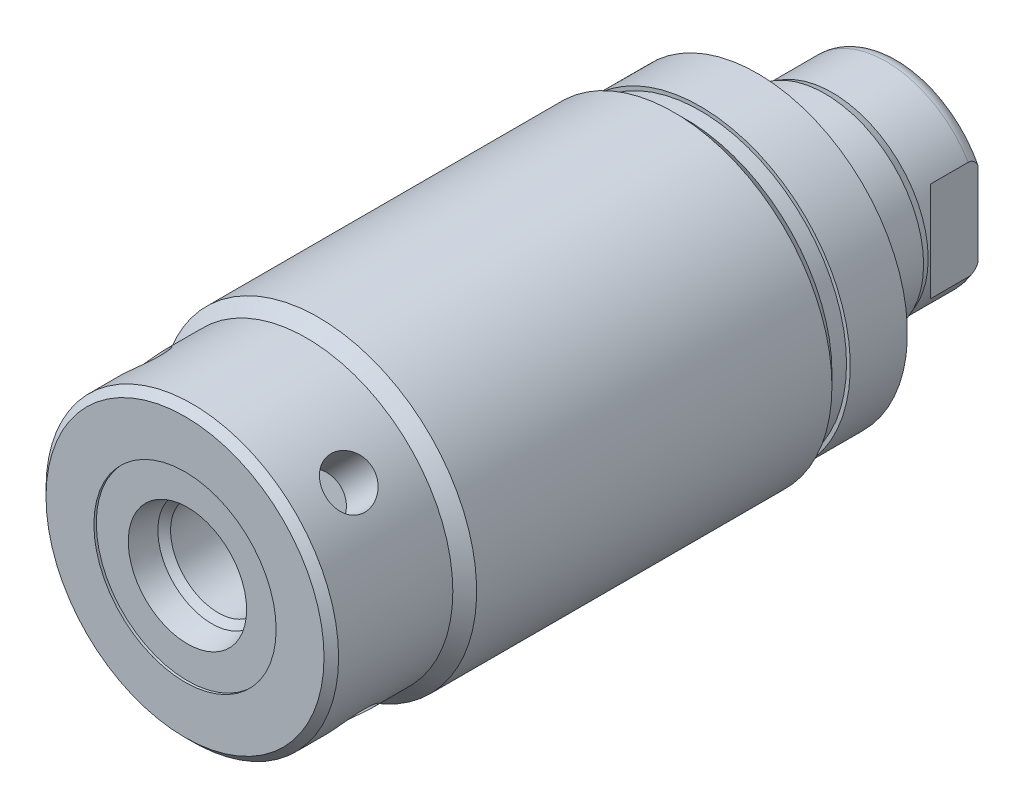
from build123d import *

# Parameters (mm, degrees)
SKETCH1_R          = 16.5354
EXTRUDE1_DEPTH     = 53.848
CHAMFER1_SIZE      = 0.762
SKETCH6_R          = 15.6845
EXTRUDE2_DEPTH     = 5.969
SKETCH7_W          = 14.478
SKETCH7_H          = 10.31875
CUT_EXTRUDE4_DEPTH = 19.84248
HOLE1_D            = 5.0038
HOLE1_DEPTH        = 4.7498
CIRPATTERN1_COUNT  = 4


with BuildPart() as part:
    # Sketch1 → Extrude1 (new body)
    with BuildSketch(Plane.XY):
        Circle(SKETCH1_R)
    extrude(amount=EXTRUDE1_DEPTH)

    # Sketch2 → Cut-Revolve1 (revolve, cut)
    with BuildSketch(Plane(origin=(0, 0, 0), x_dir=(1, 0, 0), z_dir=(0, 1, 0)), mode=Mode.PRIVATE) as cut_revolve1_sk:
        Polygon((16.5354, -53.848), (16.5354, -39.9034), (15.2908, -41.148), (15.2908, -53.848), align=None)
    revolve(cut_revolve1_sk.sketch.rotate(Axis((0, 0, 0), (0, 0, 1)), 180), axis=Axis((0, 0, 0), (0, 0, 1)), mode=Mode.SUBTRACT)  # turned: the seam where the file's is

    # Sketch3 → Cut-Revolve2 (revolve, cut)
    with BuildSketch(Plane(origin=(0, 0, 0), x_dir=(1, 0, 0), z_dir=(0, 1, 0)), mode=Mode.PRIVATE) as cut_revolve2_sk:
        Polygon((15.2908, 0), (15.2908, -1.524), (16.5354, -2.7686), (16.5354, 0), align=None)
    revolve(cut_revolve2_sk.sketch.rotate(Axis((0, 0, 0), (0, 0, -1)), 180), axis=Axis((0, 0, 0), (0, 0, -1)), mode=Mode.SUBTRACT)  # turned: the seam where the file's is

    # S2D0002 → Cut-Revolve3 (revolve, cut)
    with BuildSketch(Plane(origin=(0, 0, 0), x_dir=(1, 0, 0), z_dir=(0, 1, 0))):
        Polygon((6.1849, -53.594), (9.525, -53.594), (9.525, -53.848), (0, -53.848), (0, -39.624), (4.9784, -39.624), (4.9784, -50.377393135), (5.642306865, -51.0413), align=None)
    revolve(axis=Axis((0, 0, 14.6685), (0, 0, -1)), mode=Mode.SUBTRACT)

    # Chamfer1
    chamfer1_edges = [part.edges().sort_by_distance(p)[0] for p in [
        (15.2908, 0, 53.848),
    ]]
    chamfer(chamfer1_edges, length=CHAMFER1_SIZE)

    # Sketch6 → Extrude2 (add)
    with BuildSketch(Plane(origin=(0, 0, 0), x_dir=(-1, 0, 0), z_dir=(0, 0, -1))):
        Circle(SKETCH6_R)
    extrude(amount=EXTRUDE2_DEPTH)

    # Sketch7 → Revolve1 (revolve)
    with BuildSketch(Plane(origin=(0, 0, 0), x_dir=(0, 0, -1), z_dir=(1, 0, 0)), mode=Mode.PRIVATE) as revolve1_sk:
        with Locations((13.208, -5.159375)):
            Rectangle(SKETCH7_W, SKETCH7_H)
    revolve(revolve1_sk.sketch.rotate(Axis((0, 0, 0), (0, 0, -1)), 270), axis=Axis((0, 0, 0), (0, 0, -1)))  # turned: the seam where the file's is

    # S2D0001 → Cut-Revolve5 (revolve, cut)
    with BuildSketch(Plane(origin=(0, 0, 0), x_dir=(1, 0, 0), z_dir=(0, 1, 0))):
        Polygon((3.2639, 18.511260017), (3.2639, 3.8608), (0, 3.8608), (0, 20.447), (4.3815, 20.447), align=None)
    revolve(axis=Axis((0, 0, 31.308359971), (0, 0, -1)), mode=Mode.SUBTRACT)

    # Sketch9 → Cut-Revolve6 (revolve, cut)
    with BuildSketch(Plane(origin=(0, 0, 0), x_dir=(0, -1, 0), z_dir=(1, 0, 0)), mode=Mode.PRIVATE) as cut_revolve6_sk:
        with BuildLine():
            Line((-10.31875, 13.0302), (-10.033, 13.7922))
            Line((-10.033, 13.7922), (-10.033, 19.431))
            ThreePointArc((-10.033, 19.431), (-9.932678675, 19.974796865), (-9.644922533, 20.447))
            Line((-9.644922533, 20.447), (-10.31875, 20.447))
            Line((-10.31875, 20.447), (-10.31875, 13.0302))
        make_face()
    revolve(cut_revolve6_sk.sketch.rotate(Axis((0, 0, -12.65936), (0, 0, -1)), 90), axis=Axis((0, 0, -12.65936), (0, 0, -1)), mode=Mode.SUBTRACT)  # turned: the seam where the file's is

    # Sketch13 → Cut-Extrude4 (cut, symmetric)
    with BuildSketch(Plane(origin=(0, 0, 0), x_dir=(1, 0, 0), z_dir=(0, 1, 0))):
        Polygon((8.5852, 20.447), (8.5852, 15.494), (10.033, 14.0462), (10.033, 20.447), align=None)
        Polygon((-8.5852, 20.447), (-8.5852, 15.494), (-10.033, 14.0462), (-10.033, 20.447), align=None)
    extrude(amount=CUT_EXTRUDE4_DEPTH, both=True, mode=Mode.SUBTRACT)

    # Hole1
    with Locations(Plane(origin=(-10.81222837, 10.81222837, 47.498), x_dir=(0.707106781, 0.707106781, 0), z_dir=(-0.707106781, 0.707106781, 0))):
        with Locations((0, 0)):
            hole1 = Hole(HOLE1_D / 2, depth=HOLE1_DEPTH)

    # CirPattern1: Hole1 ×4 about axis
    cirpattern1_axis = Axis((0, 0, 0), (0, 0, 1))
    for i in range(1, CIRPATTERN1_COUNT):
        add(hole1.rotate(cirpattern1_axis, i * 360 / CIRPATTERN1_COUNT), mode=Mode.SUBTRACT)


solid = part.part
